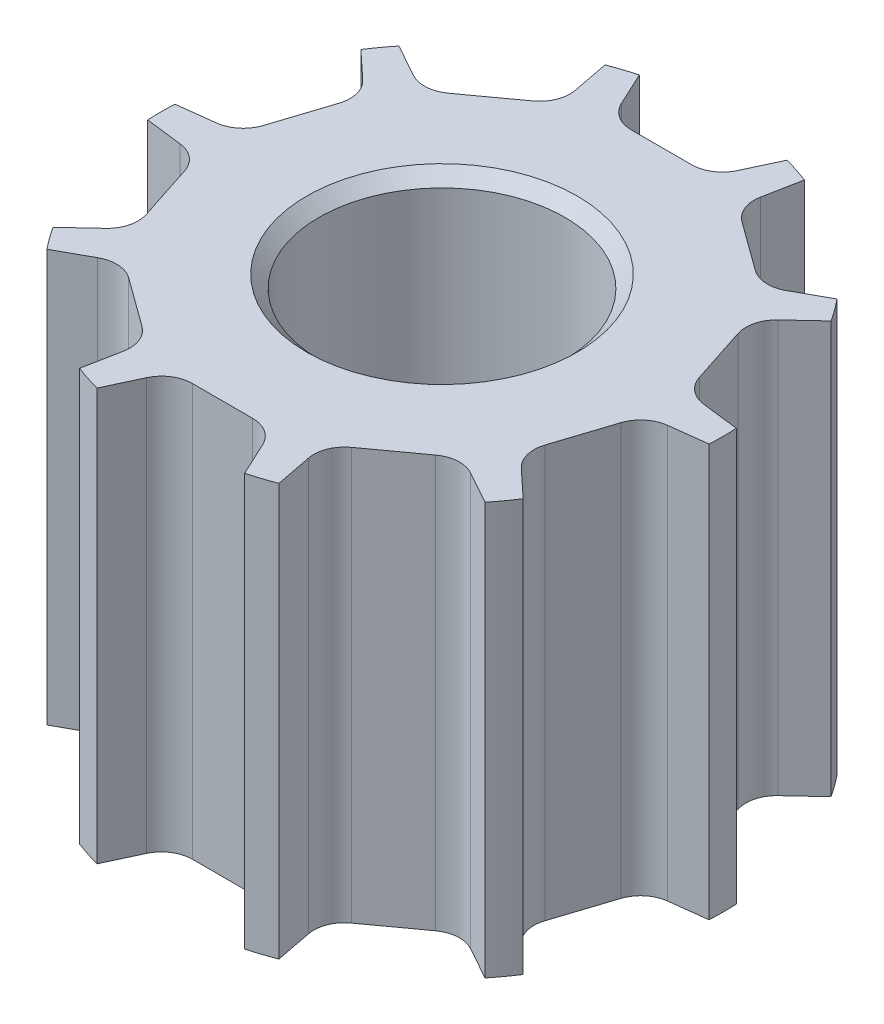
from build123d import *

# Parameters (mm, degrees)
SKIZZE1_R                       = 4.57
SKIZZE1_R_2                     = 2
AUFSATZ_LINEAR_AUSTRAGEN1_DEPTH = 6.7
SCHNITT_LINEAR_AUSTRAGEN1_DEPTH = 10.309124556
VERRUNDUNG1_R                   = 0.5
KREISMUSTER1_COUNT              = 10
VERRUNDUNG1_OF_KREISMUSTER1_R   = 0.5
FASE2_SIZE                      = 0.2


with BuildPart() as part:
    # Skizze1 → Aufsatz-Linear austragen1 (new body)
    with BuildSketch(Plane(origin=(0, 0, 0), x_dir=(1, 0, 0), z_dir=(0, 1, 0))):
        Circle(SKIZZE1_R)
        Circle(SKIZZE1_R_2, mode=Mode.SUBTRACT)
    extrude(amount=AUFSATZ_LINEAR_AUSTRAGEN1_DEPTH)

    # Skizze12 → Schnitt-Linear austragen1 (cut, through all)
    with BuildSketch(Plane(origin=(0, 6.7, 0), x_dir=(1, 0, 0), z_dir=(0, 1, 0))):
        with BuildLine():
            Line((-1.2, 4.409637173), (-0.808470756, 3.57))
            Line((-0.808470756, 3.57), (0.808470756, 3.57))
            Line((0.808470756, 3.57), (1.2, 4.409637173))
            ThreePointArc((1.2, 4.409637173), (0, 4.57), (-1.2, 4.409637173))
        make_face()
    schnitt_linear_austragen1 = extrude(amount=-SCHNITT_LINEAR_AUSTRAGEN1_DEPTH, mode=Mode.SUBTRACT)

    # Verrundung1
    verrundung1_edges = [part.edges().sort_by_distance(p)[0] for p in [
        (0.808470756, 3.35, -3.57),
        (-0.808470756, 3.35, -3.57),
    ]]
    fillet(verrundung1_edges, radius=VERRUNDUNG1_R)

    # Kreismuster1: Schnitt-Linear austragen1 ×10 about axis
    kreismuster1_axis = Axis((0, -12.75, 0), (0, 1, 0))
    for i in range(1, KREISMUSTER1_COUNT):
        add(schnitt_linear_austragen1.rotate(kreismuster1_axis, i * 360 / KREISMUSTER1_COUNT), mode=Mode.SUBTRACT)

    # Verrundung1 of Kreismuster1
    verrundung1_of_kreismuster1_edges = [part.edges().sort_by_distance(p)[0] for p in [
        (-1.44432677, 3.35, -3.363397857),
        (-2.752459932, 3.35, -2.412983483),
        (-3.14544056, 3.35, -1.872092051),
        (-3.645102966, 3.35, -0.334289289),
        (-3.645102966, 3.35, 0.334289289),
        (-3.14544056, 3.35, 1.872092051),
        (-2.752459932, 3.35, 2.412983483),
        (-1.44432677, 3.35, 3.363397857),
        (-0.808470756, 3.35, 3.57),
        (0.808470756, 3.35, 3.57),
        (1.44432677, 3.35, 3.363397857),
        (2.752459932, 3.35, 2.412983483),
        (3.14544056, 3.35, 1.872092051),
        (3.645102966, 3.35, 0.334289289),
        (3.645102966, 3.35, -0.334289289),
        (3.14544056, 3.35, -1.872092051),
        (2.752459932, 3.35, -2.412983483),
        (1.44432677, 3.35, -3.363397857),
    ]]
    fillet(verrundung1_of_kreismuster1_edges, radius=VERRUNDUNG1_OF_KREISMUSTER1_R)

    # Fase2
    fase2_edges = [part.edges().sort_by_distance(p)[0] for p in [
        (-2, 6.7, 0),
        (-2, 0, 0),
    ]]
    chamfer(fase2_edges, length=FASE2_SIZE)


solid = part.part
